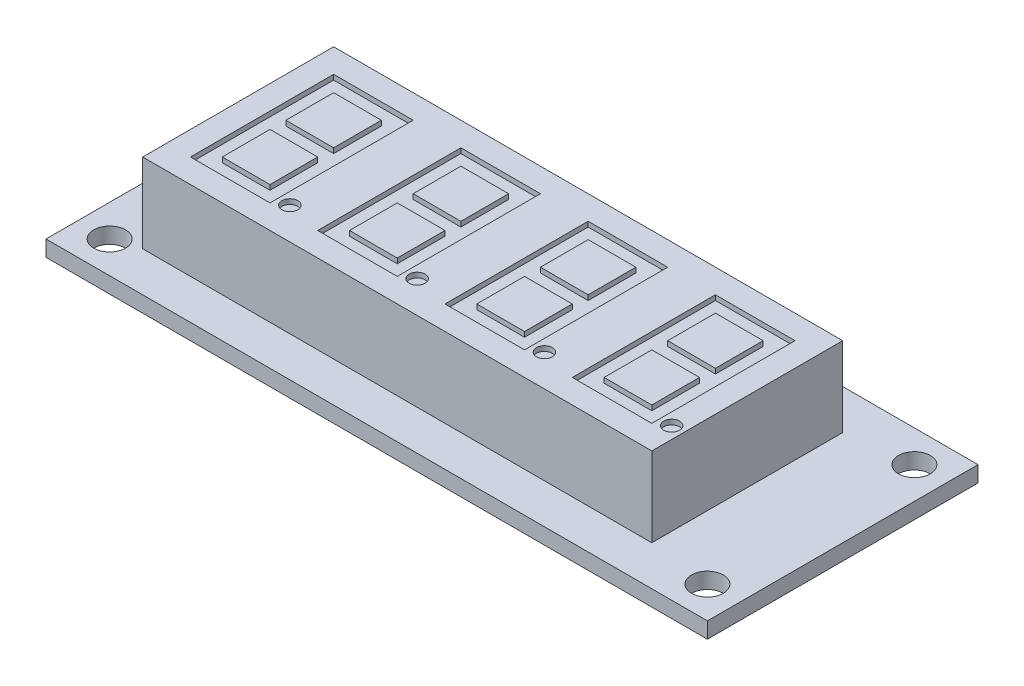
from build123d import *

# Parameters (mm, degrees)
SKETCH1_W           = 66
SKETCH1_H           = 27
SKETCH1_R           = 1.5875
BOSS_EXTRUDE1_DEPTH = 1.5875
SKETCH2_W           = 50.8
SKETCH2_H           = 19.05
BOSS_EXTRUDE2_DEPTH = 7.9375
SKETCH3_R           = 0.79375
SKETCH3_W           = 7.9375
SKETCH3_H           = 14.2875
SKETCH3_W_2         = 4.7625
SKETCH3_H_2         = 4.7625
CUT_EXTRUDE1_DEPTH  = 0.5
LPATTERN1_COUNT     = 4
LPATTERN1_PITCH     = 12.7


with BuildPart() as part:
    # Sketch1 → Boss-Extrude1 (new body)
    with BuildSketch(Plane(origin=(0, 0, 0), x_dir=(1, 0, 0), z_dir=(0, 1, 0))):
        with Locations((33, 13.5)):
            Rectangle(SKETCH1_W, SKETCH1_H)
        with Locations((62.825, 23.825)):
            Circle(SKETCH1_R, mode=Mode.SUBTRACT)
        with Locations((3.175, 23.825)):
            Circle(SKETCH1_R, mode=Mode.SUBTRACT)
        with Locations((3.175, 3.175)):
            Circle(SKETCH1_R, mode=Mode.SUBTRACT)
        with Locations((62.825, 3.175)):
            Circle(SKETCH1_R, mode=Mode.SUBTRACT)
    extrude(amount=BOSS_EXTRUDE1_DEPTH)

    # Sketch2 → Boss-Extrude2 (add)
    with BuildSketch(Plane(origin=(0, 1.5875, 0), x_dir=(1, 0, 0), z_dir=(0, 1, 0))):
        with Locations((31.075, 13.5)):
            Rectangle(SKETCH2_W, SKETCH2_H)
    extrude(amount=BOSS_EXTRUDE2_DEPTH)

    # Sketch3 → Cut-Extrude1 (cut)
    with BuildSketch(Plane(origin=(0, 9.525, 0), x_dir=(1, 0, 0), z_dir=(0, 1, 0))):
        with Locations((17.184375, 7.15)):
            Circle(SKETCH3_R)
        with Locations((12.025, 13.5)):
            Rectangle(SKETCH3_W, SKETCH3_H)
        with Locations((12.025, 16.675)):
            Rectangle(SKETCH3_W_2, SKETCH3_H_2, mode=Mode.SUBTRACT)
        with Locations((12.025, 10.325)):
            Rectangle(SKETCH3_W_2, SKETCH3_H_2, mode=Mode.SUBTRACT)
    cut_extrude1 = extrude(amount=-CUT_EXTRUDE1_DEPTH, mode=Mode.SUBTRACT)

    # LPattern1: Cut-Extrude1 ×4
    with Locations(*[(i * LPATTERN1_PITCH, 0, 0) for i in range(1, LPATTERN1_COUNT)]):
        add(cut_extrude1, mode=Mode.SUBTRACT)


solid = part.part
